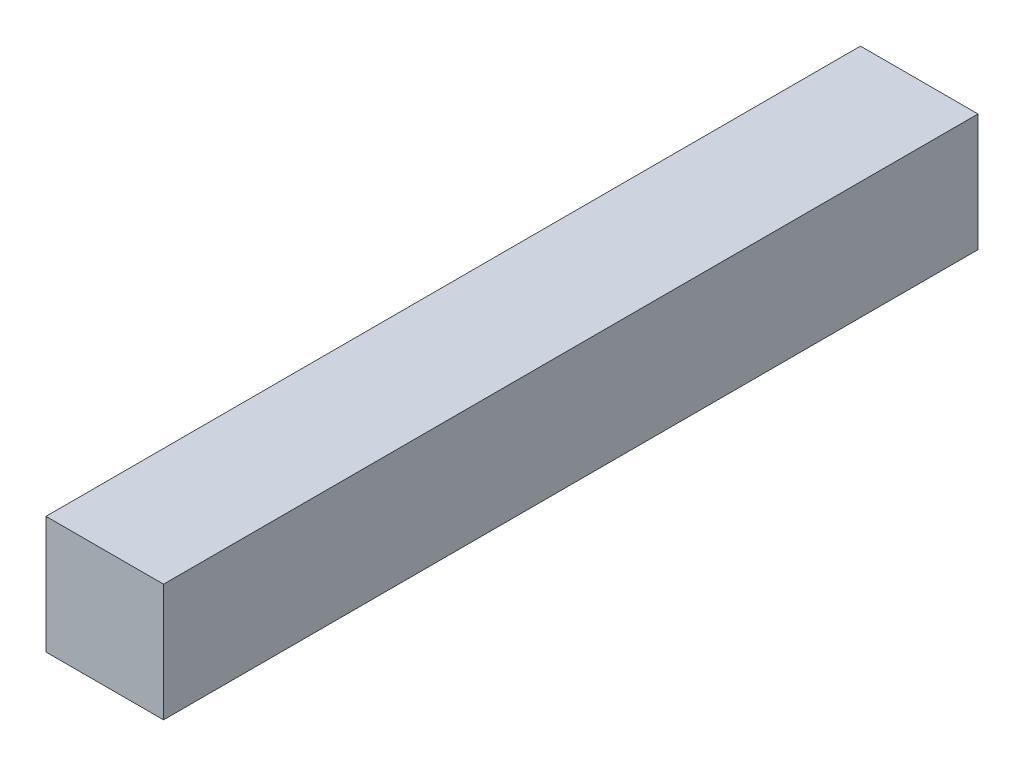
from build123d import *

# Parameters (mm, degrees)
SKETCH1_W           = 6.35
SKETCH1_H           = 6.35
BOSS_EXTRUDE1_DEPTH = 22


with BuildPart() as part:
    # Sketch1 → Boss-Extrude1 (new, symmetric)
    with BuildSketch(Plane.XY):
        Rectangle(SKETCH1_W, SKETCH1_H)
    extrude(amount=BOSS_EXTRUDE1_DEPTH, both=True)


solid = part.part
